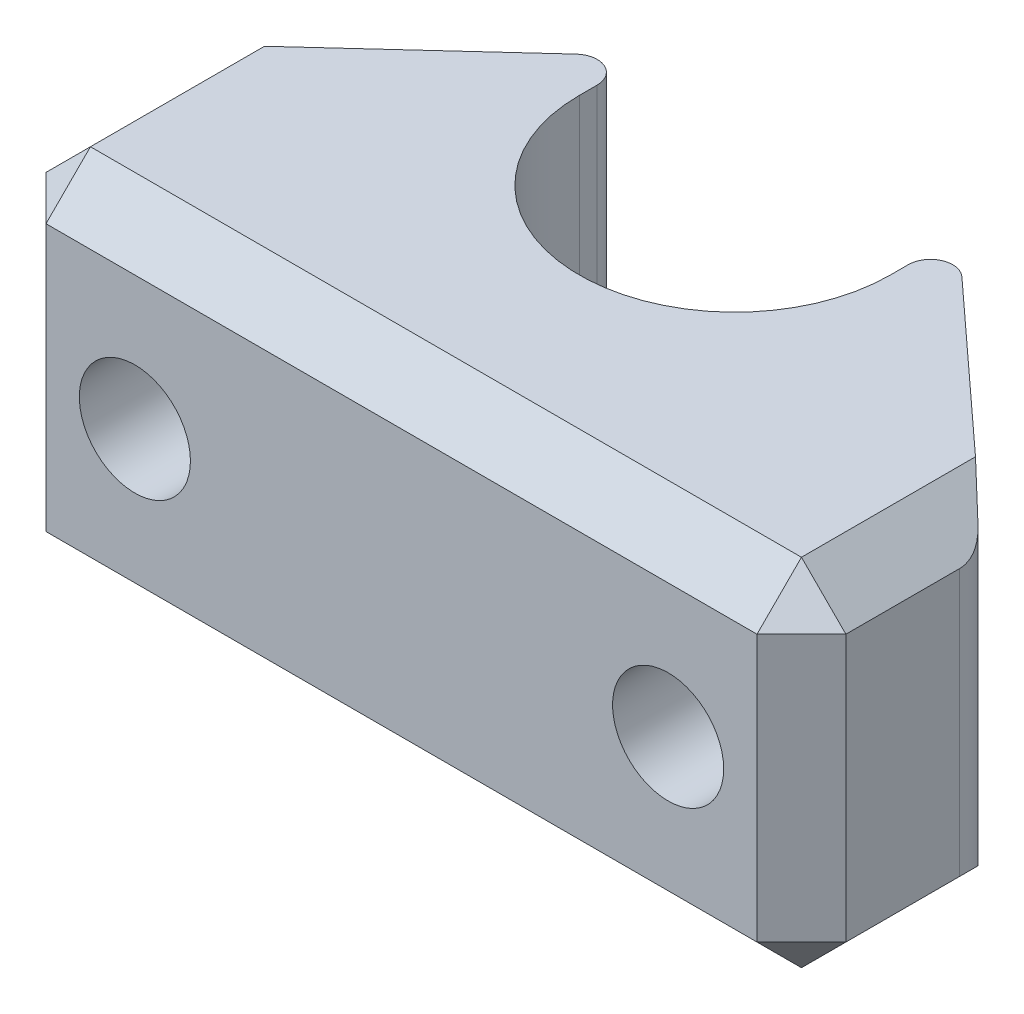
from build123d import *

# Parameters (mm, degrees)
SKETCH_1_R          = 2
EXTRUDE_1_DEPTH     = 4
HOLE_WIZARD_M3_1_D  = 2.5
CUT_EXTRUDE_1_DEPTH = 5
CHAMFER_1_SIZE      = 1
FILLET_1_R          = 1
FILLET_2_R          = 0.5


with BuildPart() as part:
    # 草图1 → 凸台-拉伸1 (new body, symmetric)
    with BuildSketch(Plane(origin=(0, 0, 0), x_dir=(1, 0, 0), z_dir=(0, 1, 0))):
        with BuildLine():
            Line((9, -7.5), (-9, -7.5))
            Line((-9, -7.5), (-9, -3.5))
            Line((-9, -3.5), (-2.36461126, 2.580428954))
            ThreePointArc((-2.36461126, 2.580428954), (0, 3.5), (2.36461126, 2.580428954))
            Line((2.36461126, 2.580428954), (9, -3.5))
            Line((9, -3.5), (9, -7.5))
        make_face()
        Circle(SKETCH_1_R, mode=Mode.SUBTRACT)
    extrude(amount=EXTRUDE_1_DEPTH, both=True)

    # M3 螺纹孔1 (through all)
    with Locations(Plane.XY.offset(7.5)):
        with Locations((-6, 0), (6, 0)):
            Hole(HOLE_WIZARD_M3_1_D / 2)

    # 草图4 → 切除-拉伸1 (cut)
    with BuildSketch(Plane(origin=(0, 4, 0), x_dir=(1, 0, 0), z_dir=(0, 1, 0))):
        with BuildLine():
            Line((-3.5, 0), (-3.5, 1.54))
            Line((-3.5, 1.54), (-2.36461126, 2.580428954))
            ThreePointArc((-2.36461126, 2.580428954), (0, 3.5), (2.36461126, 2.580428954))
            Line((2.36461126, 2.580428954), (3.5, 1.54))
            Line((3.5, 1.54), (3.5, 0))
            ThreePointArc((3.5, 0), (0, -3.5), (-3.5, 0))
        make_face()
    extrude(amount=-CUT_EXTRUDE_1_DEPTH, mode=Mode.SUBTRACT)

    # 倒角1
    chamfer_1_edges = [part.edges().sort_by_distance(p)[0] for p in [
        (9, 0, 7.5),
        (-9, 0, 7.5),
        (-9, 4, 5.5),
        (0, 4, 7.5),
        (9, 4, 5.5),
        (0, -4, 7.5),
        (-9, -4, 5.5),
        (9, -4, 5.5),
    ]]
    chamfer(chamfer_1_edges, length=CHAMFER_1_SIZE)

    # 圆角1
    fillet_1_edges = [part.edges().sort_by_distance(p)[0] for p in [
        (-9, 0, 3.5),
        (9, 0, 3.5),
    ]]
    fillet(fillet_1_edges, radius=FILLET_1_R)

    # 圆角2
    fillet_2_edges = [part.edges().sort_by_distance(p)[0] for p in [
        (-3.5, 1.5, -1.54),
        (3.5, 1.5, -1.54),
    ]]
    fillet(fillet_2_edges, radius=FILLET_2_R)


solid = part.part
